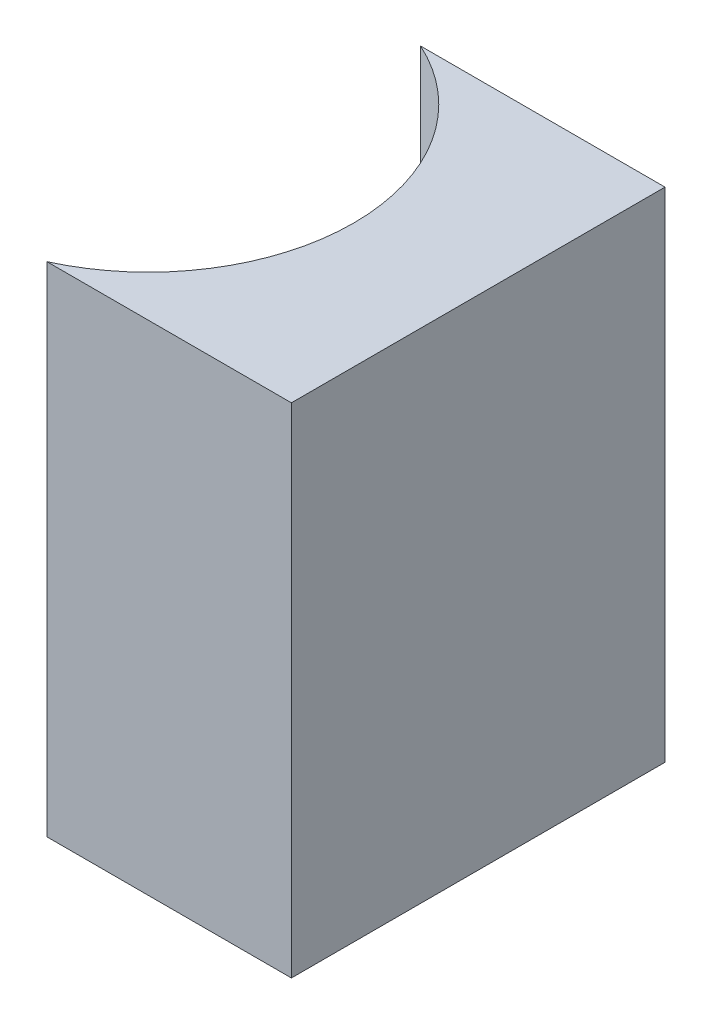
from build123d import *

# Parameters (mm, degrees)
EXTRUDE_1_DEPTH = 8


with BuildPart() as part:
    # 草图1 → 凸台-拉伸1 (new body)
    with BuildSketch(Plane(origin=(0, 0, 0), x_dir=(1, 0, 0), z_dir=(0, 1, 0))):
        with BuildLine():
            Line((0, 0), (0, -6))
            Line((0, -6), (-3.925227292, -6))
            ThreePointArc((-3.925227292, -6), (-2, -3), (-3.925227292, 0))
            Line((-3.925227292, 0), (0, 0))
        make_face()
    extrude(amount=EXTRUDE_1_DEPTH)


solid = part.part
